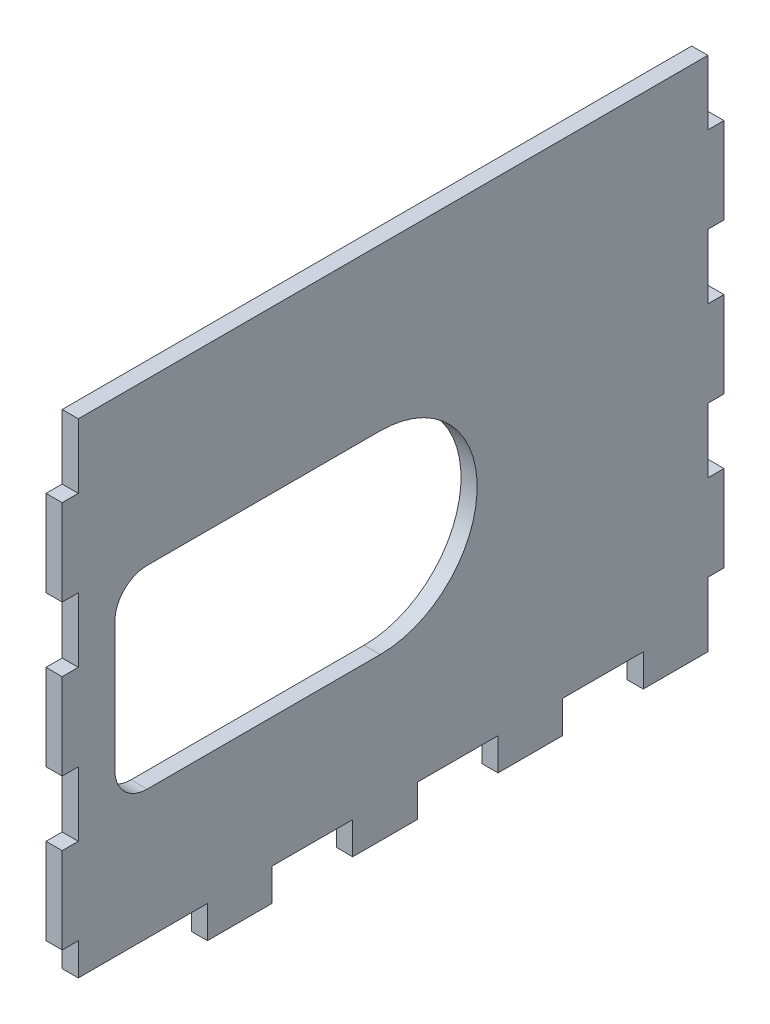
from build123d import *

# Parameters (mm, degrees)
SKETCH1_W               = 44.958
SKETCH1_H               = 304.8
BOSS_EXTRUDE1_DEPTH     = 3.175
BOSS_EXTRUDE2_DEPTH     = 3.175
SKETCH3_W               = 123.825
SKETCH3_H               = 6.35
BOSS_EXTRUDE3_DEPTH     = 41.783
SKETCH8_W               = 3.175
SKETCH8_H               = 213.451350416
CUT_EXTRUDE4_DEPTH      = 1
CUT_EXTRUDE4_DEPTH_BACK = 131.175
SKETCH6_W               = 3.175
SKETCH6_H               = 12.7
CUT_EXTRUDE5_DEPTH      = 3.175
SKETCH4_3_W             = 6.35
SKETCH4_3_H             = 15.875
SKETCH4_3_H_2           = 5.588
SKETCH4_3_H_3           = 7.112
CUT_EXTRUDE6_DEPTH      = 6.35
CUT_EXTRUDE7_DEPTH      = 4.175


with BuildPart() as part:
    # Sketch1 → Boss-Extrude1 (new body)
    with BuildSketch(Plane.XY):
        with Locations((-6.477, 3.048)):
            Rectangle(SKETCH1_W, SKETCH1_H)
        with BuildLine():
            Line((-3.302, 133.858), (-3.302, -143.002))
            Line((-3.302, -143.002), (3.302, -143.002))
            Line((3.302, -143.002), (3.302, 143.002))
            Line((3.302, 143.002), (-16.256, 143.002))
            Line((-16.256, 143.002), (-16.256, 136.398))
            Line((-16.256, 136.398), (-5.842, 136.398))
            ThreePointArc((-5.842, 136.398), (-4.045948776, 135.654051224), (-3.302, 133.858))
        make_face(mode=Mode.SUBTRACT)
    extrude(amount=BOSS_EXTRUDE1_DEPTH)

    # Sketch2 → Boss-Extrude2 (add)
    with BuildSketch(Plane(origin=(16.002, 0, 0), x_dir=(0, 0, -1), z_dir=(1, 0, 0))):
        Polygon((123.825, -47.752), (-3.175, -47.752), (-3.175, -149.352), (123.825, -149.352), (123.825, -136.652), (127, -136.652), (127, -119.718666667), (123.825, -119.718666667), (123.825, -107.018666667), (127, -107.018666667), (127, -90.085333333), (123.825, -90.085333333), (123.825, -77.385333333), (127, -77.385333333), (127, -60.452), (123.825, -60.452), align=None)
        with BuildLine():
            ThreePointArc((11.9, -106.092), (10.4, -107.592), (8.9, -106.092))
            Line((8.9, -106.092), (8.9, -101.012))
            ThreePointArc((8.9, -101.012), (10.4, -99.512), (11.9, -101.012))
            Line((11.9, -101.012), (11.9, -106.092))
        make_face(mode=Mode.SUBTRACT)
        with BuildLine():
            ThreePointArc((60.9, -106.092), (59.4, -107.592), (57.9, -106.092))
            Line((57.9, -106.092), (57.9, -101.012))
            ThreePointArc((57.9, -101.012), (59.4, -99.512), (60.9, -101.012))
            Line((60.9, -101.012), (60.9, -106.092))
        make_face(mode=Mode.SUBTRACT)
        with BuildLine():
            Line((8.9, -96.092), (8.9, -91.012))
            ThreePointArc((8.9, -91.012), (10.4, -89.512), (11.9, -91.012))
            Line((11.9, -91.012), (11.9, -96.092))
            ThreePointArc((11.9, -96.092), (10.4, -97.592), (8.9, -96.092))
        make_face(mode=Mode.SUBTRACT)
        with BuildLine():
            ThreePointArc((36.4, -101.092), (25.4, -112.092), (14.4, -101.092))
            Line((14.4, -101.092), (14.4, -96.012))
            ThreePointArc((14.4, -96.012), (25.4, -85.012), (36.4, -96.012))
            Line((36.4, -96.012), (36.4, -101.092))
        make_face(mode=Mode.SUBTRACT)
        with BuildLine():
            ThreePointArc((57.9, -91.012), (59.4, -89.512), (60.9, -91.012))
            Line((60.9, -91.012), (60.9, -96.092))
            ThreePointArc((60.9, -96.092), (59.4, -97.592), (57.9, -96.092))
            Line((57.9, -96.092), (57.9, -91.012))
        make_face(mode=Mode.SUBTRACT)
    extrude(amount=-BOSS_EXTRUDE2_DEPTH)

    # Sketch3 → Boss-Extrude3 (add)
    with BuildSketch(Plane.ZY.offset(-12.827)):
        with Locations((-61.9125, -146.177)):
            Rectangle(SKETCH3_W, SKETCH3_H)
    extrude(amount=BOSS_EXTRUDE3_DEPTH)

    # Sketch8 → Cut-Extrude4 (cut, two sides)
    with BuildSketch(Plane.XY.offset(3.175)) as cut_extrude4_sk:
        Polygon((-28.956, -149.352), (12.827, -149.352), (12.827, -47.752), (12.827, 155.448), (-28.956, 155.448), align=None)
        with BuildLine():
            Line((-16.256, 136.398), (-16.256, 143.002))
            Line((-16.256, 143.002), (3.302, 143.002))
            Line((3.302, 143.002), (3.302, -143.002))
            Line((3.302, -143.002), (-3.302, -143.002))
            Line((-3.302, -143.002), (-3.302, 133.858))
            ThreePointArc((-3.302, 133.858), (-4.045948776, 135.654051224), (-5.842, 136.398))
            Line((-5.842, 136.398), (-16.256, 136.398))
        make_face(mode=Mode.SUBTRACT)
        Polygon((-54.223542679, -149.352), (-28.956, -149.352), (-28.956, 155.448), (12.827, 155.448), (12.827, 165.699350416), (-54.223542679, 165.699350416), align=None)
        with Locations((14.4145, 58.973675208)):
            Rectangle(SKETCH8_W, SKETCH8_H)
    extrude(amount=CUT_EXTRUDE4_DEPTH, mode=Mode.SUBTRACT)
    extrude(cut_extrude4_sk.sketch, amount=-CUT_EXTRUDE4_DEPTH_BACK, mode=Mode.SUBTRACT)

    # Sketch6 → Cut-Extrude5 (cut)
    with BuildSketch(Plane.XY.offset(3.175)):
        with Locations((14.4145, -54.102)):
            Rectangle(SKETCH6_W, SKETCH6_H)
        with Locations((14.4145, -83.735333333)):
            Rectangle(SKETCH6_W, SKETCH6_H)
        with Locations((14.4145, -113.368666667)):
            Rectangle(SKETCH6_W, SKETCH6_H)
        with Locations((14.4145, -143.002)):
            Rectangle(SKETCH6_W, SKETCH6_H)
    extrude(amount=-CUT_EXTRUDE5_DEPTH, mode=Mode.SUBTRACT)

    # Sketch4_3 → Cut-Extrude6 (cut)
    with BuildSketch(Plane.XZ.offset(149.352)):
        with Locations((12.827, -103.1875)):
            Rectangle(SKETCH4_3_W, SKETCH4_3_H)
        with Locations((12.827, -74.6125)):
            Rectangle(SKETCH4_3_W, SKETCH4_3_H)
        with Locations((12.827, -46.0375)):
            Rectangle(SKETCH4_3_W, SKETCH4_3_H)
        with Locations((12.827, -17.4625)):
            Rectangle(SKETCH4_3_W, SKETCH4_3_H)
        with Locations((12.827, 0.381)):
            Rectangle(SKETCH4_3_W, SKETCH4_3_H_2)
        with Locations((12.827, -5.969)):
            Rectangle(SKETCH4_3_W, SKETCH4_3_H_3)
    extrude(amount=-CUT_EXTRUDE6_DEPTH, mode=Mode.SUBTRACT)

    # Sketch9 → Cut-Extrude7 (cut, through all)
    with BuildSketch(Plane(origin=(16.002, 0, 0), x_dir=(0, 0, -1), z_dir=(1, 0, 0))):
        with BuildLine():
            ThreePointArc((7.197741164, -98.552), (12.777356982, -85.081615818), (26.247741164, -79.502))
            Line((26.247741164, -79.502), (13.547741164, -79.502))
            ThreePointArc((13.547741164, -79.502), (9.057613103, -81.361871939), (7.197741164, -85.852))
            Line((7.197741164, -85.852), (7.197741164, -98.552))
        make_face()
        with BuildLine():
            ThreePointArc((26.247741164, -117.602), (12.777356982, -112.022384182), (7.197741164, -98.552))
            Line((7.197741164, -98.552), (7.197741164, -111.252))
            ThreePointArc((7.197741164, -111.252), (9.057613103, -115.742128061), (13.547741164, -117.602))
            Line((13.547741164, -117.602), (26.247741164, -117.602))
        make_face()
        with BuildLine():
            Line((59.4, -79.502), (26.247741164, -79.502))
            ThreePointArc((26.247741164, -79.502), (16.074520569, -82.445849537), (9.045492178, -90.367555619))
            ThreePointArc((9.045492178, -90.367555619), (7.665419684, -94.356785058), (7.197741164, -98.552))
            ThreePointArc((7.197741164, -98.552), (7.665419676, -102.747214908), (9.045492148, -106.736444318))
            ThreePointArc((9.045492148, -106.736444318), (16.07452054, -114.658150444), (26.247741164, -117.602))
            Line((26.247741164, -117.602), (59.4, -117.602))
            ThreePointArc((59.4, -117.602), (78.45, -98.552), (59.4, -79.502))
        make_face()
        with BuildLine():
            ThreePointArc((11.9, -106.092), (10.73033182, -107.555174935), (9.045492148, -106.736444318))
            ThreePointArc((9.045492148, -106.736444318), (8.936825065, -106.42233182), (8.9, -106.092))
            Line((8.9, -106.092), (8.9, -101.012))
            ThreePointArc((8.9, -101.012), (10.4, -99.512), (11.9, -101.012))
            Line((11.9, -101.012), (11.9, -106.092))
        make_face(mode=Mode.SUBTRACT)
        with BuildLine():
            ThreePointArc((14.4, -96.012), (25.4, -85.012), (36.4, -96.012))
            Line((36.4, -96.012), (36.4, -101.092))
            ThreePointArc((36.4, -101.092), (25.4, -112.092), (14.4, -101.092))
            Line((14.4, -101.092), (14.4, -96.012))
        make_face(mode=Mode.SUBTRACT)
        with BuildLine():
            Line((60.9, -101.012), (60.9, -106.092))
            ThreePointArc((60.9, -106.092), (59.4, -107.592), (57.9, -106.092))
            Line((57.9, -106.092), (57.9, -101.012))
            ThreePointArc((57.9, -101.012), (59.4, -99.512), (60.9, -101.012))
        make_face(mode=Mode.SUBTRACT)
        with BuildLine():
            ThreePointArc((8.9, -91.012), (8.936825073, -90.681668146), (9.045492178, -90.367555619))
            ThreePointArc((9.045492178, -90.367555619), (10.730331854, -89.548825073), (11.9, -91.012))
            Line((11.9, -91.012), (11.9, -96.092))
            ThreePointArc((11.9, -96.092), (10.4, -97.592), (8.9, -96.092))
            Line((8.9, -96.092), (8.9, -91.012))
        make_face(mode=Mode.SUBTRACT)
        with BuildLine():
            Line((60.9, -91.012), (60.9, -96.092))
            ThreePointArc((60.9, -96.092), (59.4, -97.592), (57.9, -96.092))
            Line((57.9, -96.092), (57.9, -91.012))
            ThreePointArc((57.9, -91.012), (59.4, -89.512), (60.9, -91.012))
        make_face(mode=Mode.SUBTRACT)
    extrude(amount=-CUT_EXTRUDE7_DEPTH, mode=Mode.SUBTRACT)


solid = part.part
